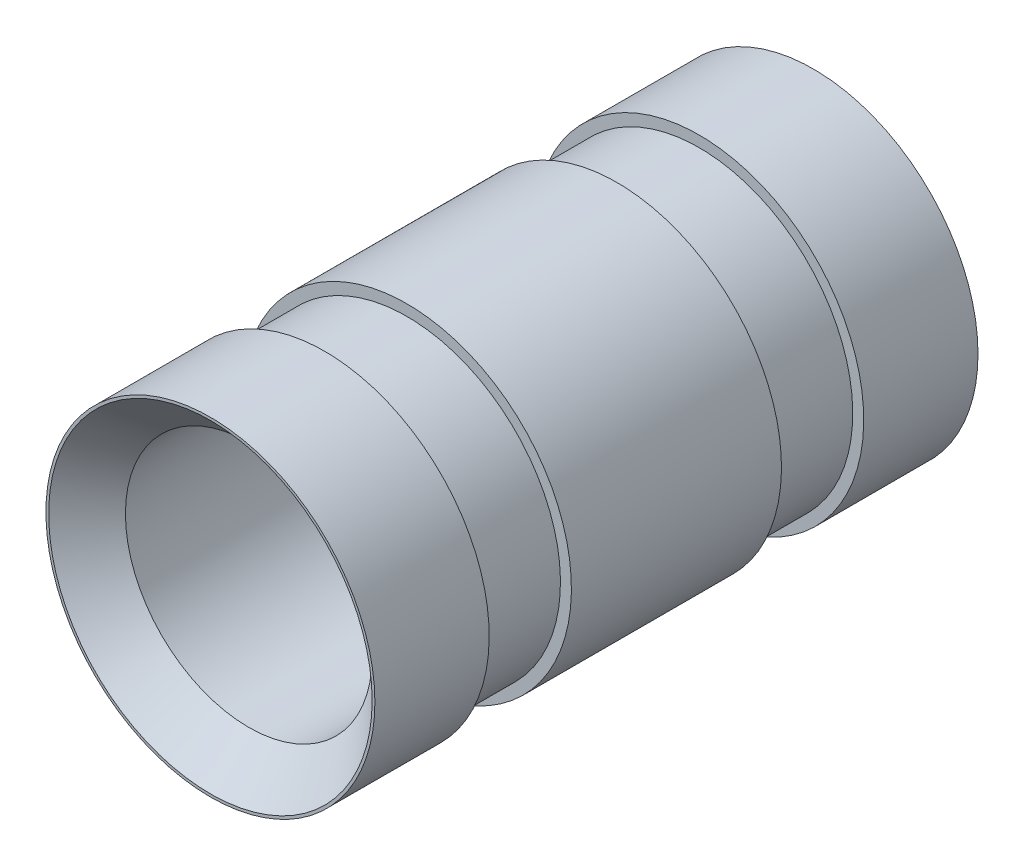
from build123d import *

# Parameters (mm, degrees)
SKETCH3_R           = 38.1
SKETCH3_R_2         = 28.575
BOSS_EXTRUDE1_DEPTH = 69.85
SKETCH4_W           = 19.05
SKETCH4_H           = 2.54
CHAMFER1_SIZE       = 8.89


with BuildPart() as part:
    # Sketch3 → Boss-Extrude1 (new, symmetric)
    with BuildSketch(Plane.XY):
        Circle(SKETCH3_R)
        Circle(SKETCH3_R_2, mode=Mode.SUBTRACT)
    extrude(amount=BOSS_EXTRUDE1_DEPTH, both=True)

    # Sketch4 → Cut-Revolve1 (revolve, cut)
    with BuildSketch(Plane(origin=(0, 0, 0), x_dir=(0, 0, -1), z_dir=(1, 0, 0)), mode=Mode.PRIVATE) as cut_revolve1_sk:
        with Locations((-33.853856194, 36.83)):
            Rectangle(SKETCH4_W, SKETCH4_H)
        with Locations((33.853856194, 36.83)):
            Rectangle(SKETCH4_W, SKETCH4_H)
    revolve(cut_revolve1_sk.sketch.rotate(Axis((0, 0, 69.85), (0, 0, -1)), 180), axis=Axis((0, 0, 69.85), (0, 0, -1)), mode=Mode.SUBTRACT)

    # Chamfer1
    chamfer1_edges = [part.edges().sort_by_distance(p)[0] for p in [
        (-28.575, 0, 69.85),
    ]]
    chamfer(chamfer1_edges, length=CHAMFER1_SIZE)


solid = part.part
